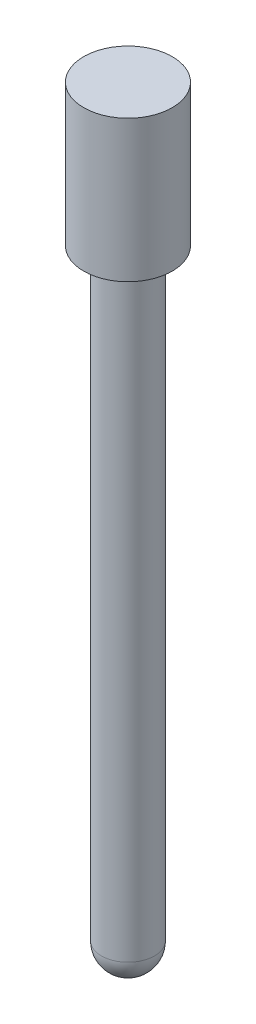
from build123d import *

# Parameters (mm, degrees)
SKETCH1_R           = 7.9375
BOSS_EXTRUDE1_DEPTH = 25.4
SKETCH2_R           = 4.7625
BOSS_EXTRUDE2_DEPTH = 107.95
DOME1_FACE_RADIUS   = 4.7625
DOME1_HEIGHT        = 4.7625


with BuildPart() as part:
    # Sketch1 → Boss-Extrude1 (new body)
    with BuildSketch(Plane(origin=(0, 0, 0), x_dir=(1, 0, 0), z_dir=(0, 1, 0))):
        with Locations(Location((0, 0, 0), (0, 0, 270))):  # turned: the seam where the file's is
            Circle(SKETCH1_R)
    extrude(amount=BOSS_EXTRUDE1_DEPTH)

    # Sketch2 → Boss-Extrude2 (add)
    with BuildSketch(Plane.XZ):
        with Locations(Location((0, 0, 0), (0, 0, 90))):  # turned: the seam where the file's is
            Circle(SKETCH2_R)
    extrude(amount=BOSS_EXTRUDE2_DEPTH)

    # Dome1: a dome of height H over a round flat face of radius A is a cap of a sphere of radius (A * A + H * H) / (2 * H)
    dome1_r = (DOME1_FACE_RADIUS * DOME1_FACE_RADIUS + DOME1_HEIGHT * DOME1_HEIGHT) / (2 * DOME1_HEIGHT)
    dome1_base = Plane((0, -107.95, 0), z_dir=(0, -1, 0))
    with Locations(dome1_base.offset(DOME1_HEIGHT - dome1_r)):
        dome1_ball = Sphere(dome1_r, mode=Mode.PRIVATE)
    add(split(dome1_ball, bisect_by=dome1_base, keep=Keep.TOP, mode=Mode.PRIVATE))


solid = part.part
